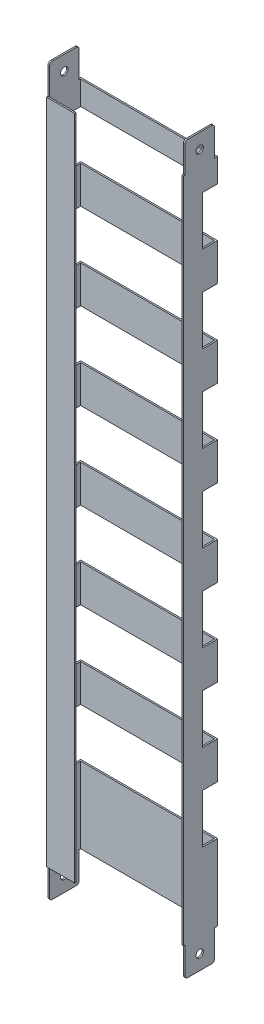
from build123d import *

# Parameters (mm, degrees)
BOSS_EXTRUDE1_DEPTH = 448
SKETCH2_W           = 1
SKETCH2_H           = 20
BOSS_EXTRUDE2_DEPTH = 20
SKETCH3_W           = 1
SKETCH3_H           = 20
BOSS_EXTRUDE3_DEPTH = 20
FILLET1_R           = 2
SKETCH4_W           = 10
SKETCH4_H           = 33
CUT_EXTRUDE1_DEPTH  = 93
LPATTERN1_COUNT     = 7
LPATTERN1_PITCH     = 58
SKETCH5_R           = 2.5
CUT_EXTRUDE2_DEPTH  = 93


with BuildPart() as part:
    # Sketch1 → Boss-Extrude1 (new body)
    with BuildSketch(Plane(origin=(0, 0, 0), x_dir=(1, 0, 0), z_dir=(0, 1, 0))):
        Polygon((0, 0), (0, 1), (-18, 1), (-18, 22), (72, 22), (72, 0), (73, 0), (73, 23), (-19, 23), (-19, 0), align=None)
    extrude(amount=BOSS_EXTRUDE1_DEPTH)

    # Sketch2 → Boss-Extrude2 (add)
    with BuildSketch(Plane(origin=(0, 448, 0), x_dir=(1, 0, 0), z_dir=(0, 1, 0))):
        with Locations((-18.5, 11)):
            Rectangle(SKETCH2_W, SKETCH2_H)
        with Locations((72.5, 11)):
            Rectangle(SKETCH2_W, SKETCH2_H)
    extrude(amount=BOSS_EXTRUDE2_DEPTH)

    # Sketch3 → Boss-Extrude3 (add)
    with BuildSketch(Plane(origin=(0, 0, 0), x_dir=(-1, 0, 0), z_dir=(0, -1, 0))):
        with Locations((18.5, 11)):
            Rectangle(SKETCH3_W, SKETCH3_H)
        with Locations((-72.5, 11)):
            Rectangle(SKETCH3_W, SKETCH3_H)
    extrude(amount=BOSS_EXTRUDE3_DEPTH)

    # Fillet1
    fillet1_edges = [part.edges().sort_by_distance(p)[0] for p in [
        (-18.5, 468, -21),
        (-18.5, 468, -1),
        (72.5, 468, -1),
        (72.5, 468, -21),
        (-18.5, -20, -1),
        (-18.5, -20, -21),
        (72.5, -20, -21),
        (72.5, -20, -1),
    ]]
    fillet(fillet1_edges, radius=FILLET1_R)

    # Sketch4 → Cut-Extrude1 (cut, through all)
    with BuildSketch(Plane(origin=(73, 0, 0), x_dir=(0, 0, -1), z_dir=(1, 0, 0))):
        with Locations((18, 415.5)):
            Rectangle(SKETCH4_W, SKETCH4_H)
    cut_extrude1 = extrude(amount=-CUT_EXTRUDE1_DEPTH, mode=Mode.SUBTRACT)

    # LPattern1: Cut-Extrude1 ×7
    with Locations(*[(0, -i * LPATTERN1_PITCH, 0) for i in range(1, LPATTERN1_COUNT)]):
        add(cut_extrude1, mode=Mode.SUBTRACT)

    # Sketch5 → Cut-Extrude2 (cut, through all)
    with BuildSketch(Plane(origin=(73, 0, 0), x_dir=(0, 0, -1), z_dir=(1, 0, 0))):
        with Locations((11, 458)):
            Circle(SKETCH5_R)
        with Locations((11, -10)):
            Circle(SKETCH5_R)
    extrude(amount=-CUT_EXTRUDE2_DEPTH, mode=Mode.SUBTRACT)


solid = part.part
